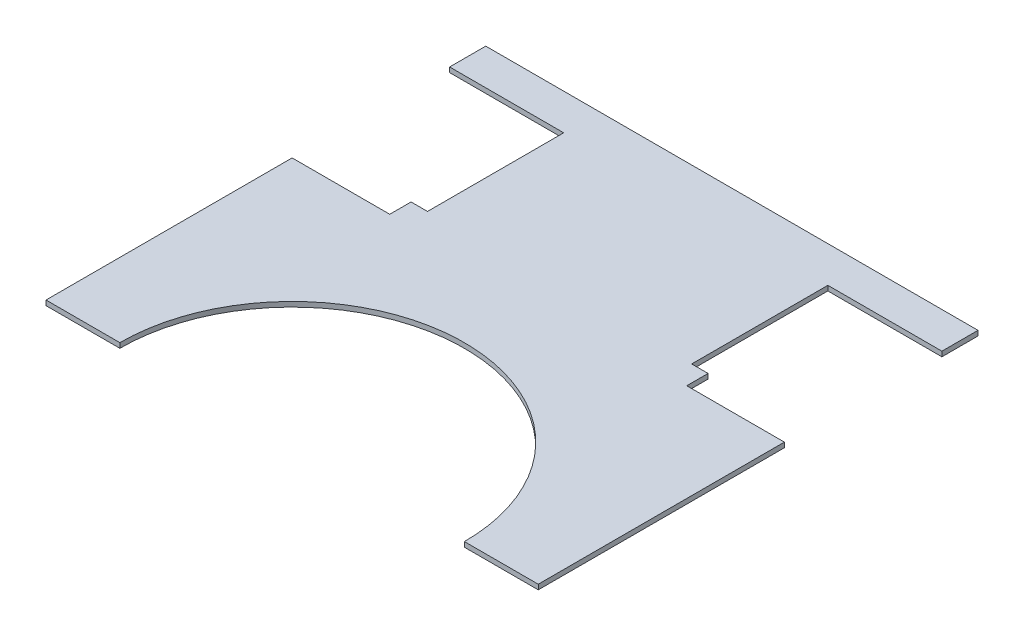
from build123d import *

# Parameters (mm, degrees)
EXTRUSION1_DEPTH = 3


with BuildPart() as part:
    # Esquisse1 → Extrusion1 (new body)
    with BuildSketch(Plane(origin=(0, 0, 0), x_dir=(1, 0, 0), z_dir=(0, 1, 0))):
        with BuildLine():
            Line((150, 0), (-150, 0))
            Line((-150, 0), (-150, -22))
            Line((-150, -22), (-80.5, -22))
            Line((-80.5, -22), (-80.5, -105))
            Line((-80.5, -105), (-90.5, -105))
            Line((-90.5, -105), (-90.5, -118))
            Line((-90.5, -118), (-150, -118))
            Line((-150, -118), (-150, -268))
            Line((-150, -268), (-105, -268))
            ThreePointArc((-105, -268), (0, -163), (105, -268))
            Line((105, -268), (150, -268))
            Line((150, -268), (150, -118))
            Line((150, -118), (90.5, -118))
            Line((90.5, -118), (90.5, -105))
            Line((90.5, -105), (80.5, -105))
            Line((80.5, -105), (80.5, -22))
            Line((80.5, -22), (150, -22))
            Line((150, -22), (150, 0))
        make_face()
    extrude(amount=EXTRUSION1_DEPTH)


solid = part.part
